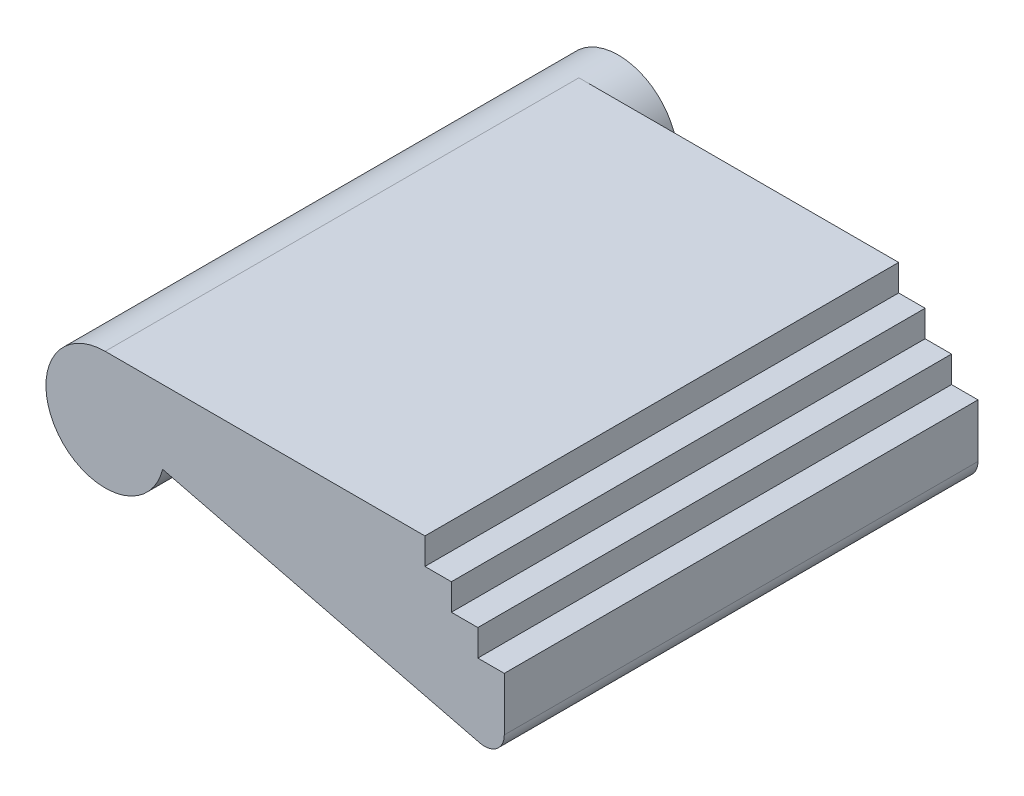
from build123d import *

# Parameters (mm, degrees)
SKETCH_1_R      = 1.5
EXTRUDE_1_DEPTH = 13
EXTRUDE_2_DEPTH = 12
FILLET_1_R      = 0.5


with BuildPart() as part:
    # 草图1 → 凸台-拉伸1 (new body)
    with BuildSketch(Plane.XY):
        Circle(SKETCH_1_R)
    extrude(amount=EXTRUDE_1_DEPTH)

    # 草图2 → 凸台-拉伸2 (add)
    with BuildSketch(Plane.XY.offset(13)):
        Polygon((0, 1.5), (8.1, 1.5), (8.1, 0.83), (8.77, 0.83), (8.77, 0.16), (9.44, 0.16), (9.44, -0.51), (10.11, -0.51), (10.11, -2.5), (0, 0), align=None)
    extrude(amount=-EXTRUDE_2_DEPTH)

    # 圆角1
    fillet_1_edges = [part.edges().sort_by_distance(p)[0] for p in [
        (10.11, -2.5, 7),
    ]]
    fillet(fillet_1_edges, radius=FILLET_1_R)


solid = part.part
